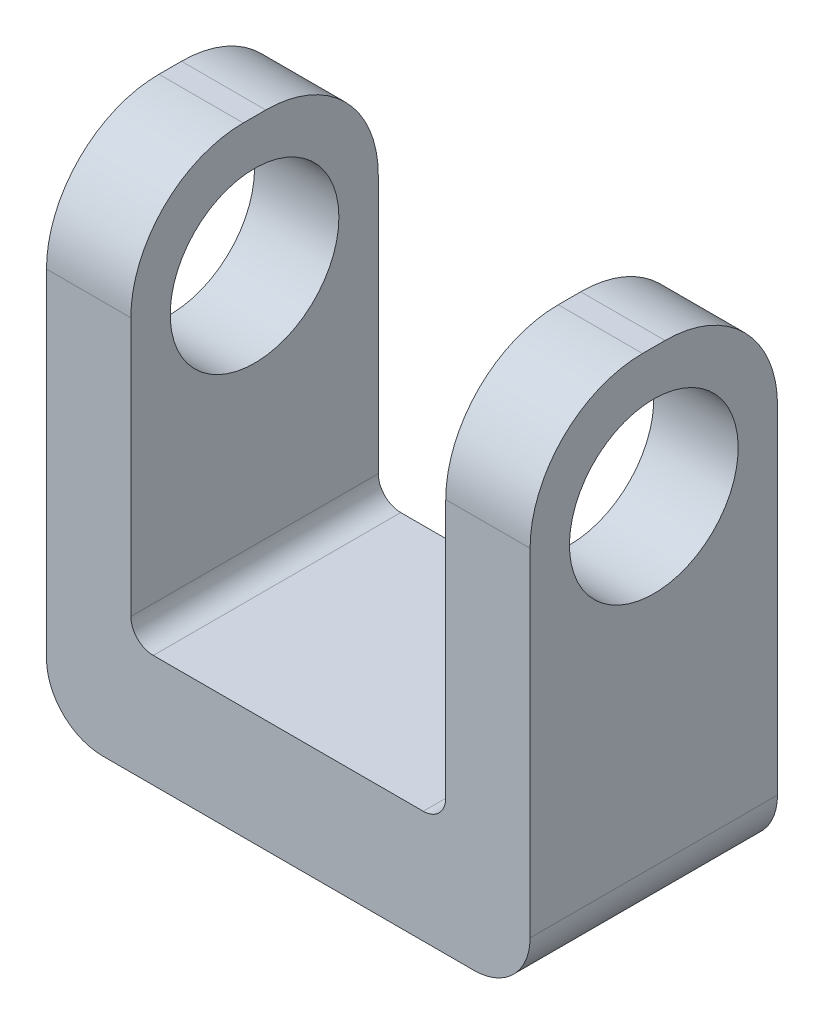
from build123d import *

# Parameters (mm, degrees)
SZKIC1_W                    = 43
SZKIC1_H                    = 45
DODANIE_WYCI_GNI_CIE1_DEPTH = 22
SZKIC3_W                    = 28
SZKIC3_H                    = 35
WYTNIJ_WYCI_GNI_CIE1_DEPTH  = 63
SZKIC4_R                    = 7.5
WYTNIJ_WYCI_GNI_CIE2_DEPTH  = 63
ZAOKR_GLENIE1_R             = 10
ZAOKR_GLENIE2_R             = 2
ZAOKR_GLENIE3_R             = 5


with BuildPart() as part:
    # Szkic1 → Dodanie-wyciągnięcie1 (new body)
    with BuildSketch(Plane.XY):
        with Locations((0, 22.5)):
            Rectangle(SZKIC1_W, SZKIC1_H)
    extrude(amount=DODANIE_WYCI_GNI_CIE1_DEPTH)

    # Szkic3 → Wytnij-wyciągnięcie1 (cut)
    with BuildSketch(Plane.XY):
        with Locations((0, 27.5)):
            Rectangle(SZKIC3_W, SZKIC3_H)
    extrude(amount=WYTNIJ_WYCI_GNI_CIE1_DEPTH, mode=Mode.SUBTRACT)

    # Szkic4 → Wytnij-wyciągnięcie2 (cut)
    with BuildSketch(Plane(origin=(21.5, 0, 0), x_dir=(0, 0, -1), z_dir=(1, 0, 0))):
        with Locations((-11, 33.5)):
            Circle(SZKIC4_R)
    extrude(amount=-WYTNIJ_WYCI_GNI_CIE2_DEPTH, mode=Mode.SUBTRACT)

    # Zaokrąglenie1
    zaokr_glenie1_edges = [part.edges().sort_by_distance(p)[0] for p in [
        (-17.75, 45, 0),
        (-17.75, 45, 22),
        (17.75, 45, 22),
        (17.75, 45, 0),
    ]]
    fillet(zaokr_glenie1_edges, radius=ZAOKR_GLENIE1_R)

    # Zaokrąglenie2
    zaokr_glenie2_edges = [part.edges().sort_by_distance(p)[0] for p in [
        (14, 10, 11),
        (-14, 10, 11),
    ]]
    fillet(zaokr_glenie2_edges, radius=ZAOKR_GLENIE2_R)

    # Zaokrąglenie3
    zaokr_glenie3_edges = [part.edges().sort_by_distance(p)[0] for p in [
        (21.5, 0, 11),
        (-21.5, 0, 11),
    ]]
    fillet(zaokr_glenie3_edges, radius=ZAOKR_GLENIE3_R)


solid = part.part
